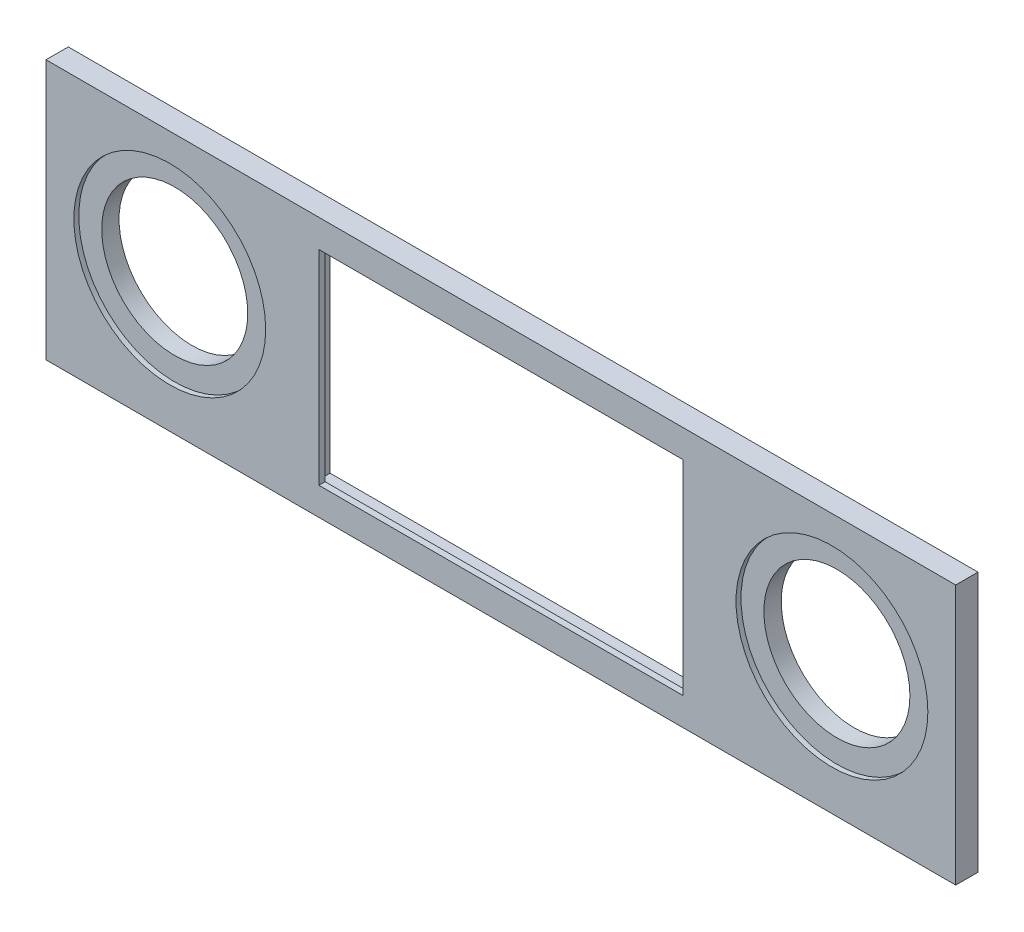
from build123d import *

# Parameters (mm, degrees)
SKETCH2_W           = 735
SKETCH2_H           = 210
SKETCH2_R           = 59
SKETCH2_W_2         = 294
SKETCH2_H_2         = 165
BOSS_EXTRUDE1_DEPTH = 18
SKETCH3_R           = 77.5
CUT_EXTRUDE1_DEPTH  = 4
SKETCH4_W           = 312
SKETCH4_H           = 175
CUT_EXTRUDE2_DEPTH  = 13


with BuildPart() as part:
    # Sketch2 → Boss-Extrude1 (new body)
    with BuildSketch(Plane.XY):
        Rectangle(SKETCH2_W, SKETCH2_H)
        with Locations((-267.5, 5)):
            Circle(SKETCH2_R, mode=Mode.SUBTRACT)
        with Locations((267.5, 5)):
            Circle(SKETCH2_R, mode=Mode.SUBTRACT)
        Rectangle(SKETCH2_W_2, SKETCH2_H_2, mode=Mode.SUBTRACT)
    extrude(amount=BOSS_EXTRUDE1_DEPTH)

    # Sketch3 → Cut-Extrude1 (cut)
    with BuildSketch(Plane.XY.offset(18)):
        with Locations((-267.5, 5)):
            Circle(SKETCH3_R)
        with Locations((267.5, 5)):
            Circle(SKETCH3_R)
    extrude(amount=-CUT_EXTRUDE1_DEPTH, mode=Mode.SUBTRACT)

    # Sketch4 → Cut-Extrude2 (cut)
    with BuildSketch(Plane(origin=(0, 0, 0), x_dir=(-1, 0, 0), z_dir=(0, 0, -1))):
        Rectangle(SKETCH4_W, SKETCH4_H)
    extrude(amount=-CUT_EXTRUDE2_DEPTH, mode=Mode.SUBTRACT)


solid = part.part
